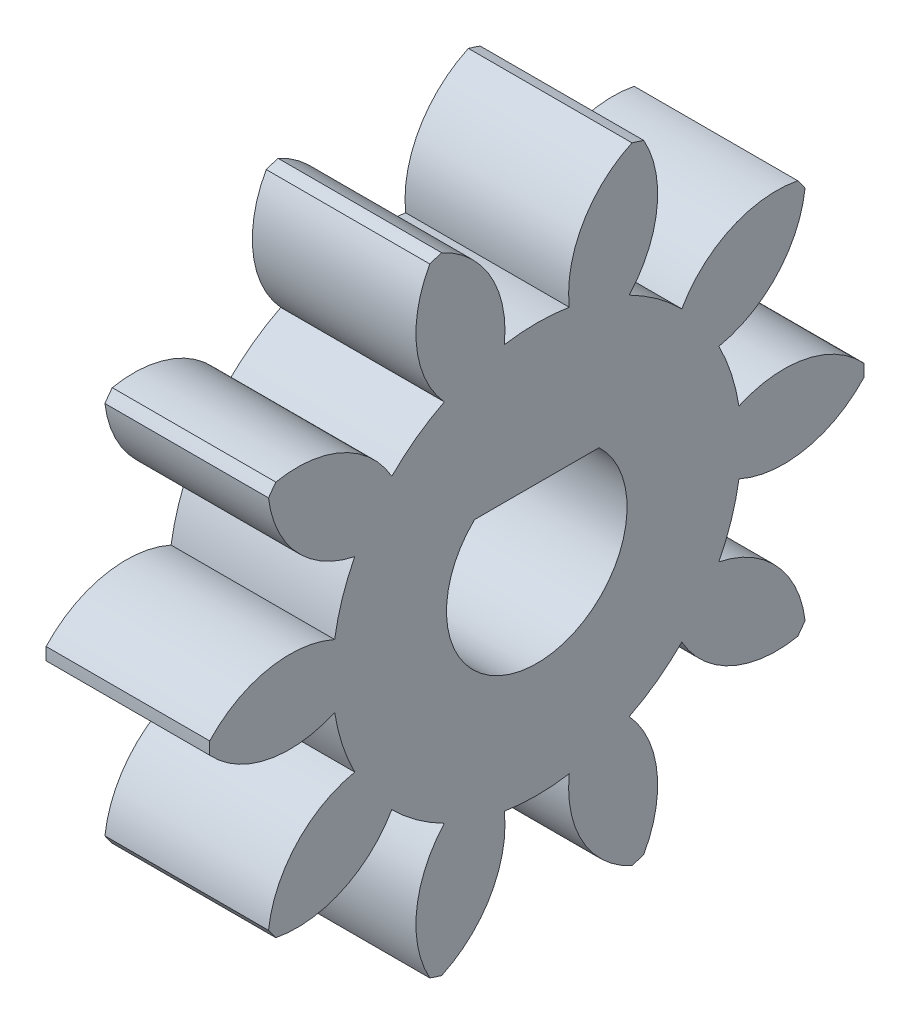
from build123d import *

# Parameters (mm, degrees)
BASPROSKE_W        = 3.175
BASPROSKE_H        = 6.35
TOOTHCUT_DEPTH     = 10.525
TEETHCUTS_COUNT    = 10
TEETHCUTS_ANGLE    = 324
BORSKE_R           = 0.99949
BORE_DEPTH         = 50.8000508
CUT_EXTRUDE1_DEPTH = 10.344170464


with BuildPart() as part:
    # BasProSke → Base-Revolve (revolve)
    with BuildSketch(Plane(origin=(0, 0, 0), x_dir=(1, 0, 0), z_dir=(0, 1, 0)), mode=Mode.PRIVATE) as base_revolve_sk:
        with Locations((1.5875, 3.175)):
            Rectangle(BASPROSKE_W, BASPROSKE_H)
    revolve(base_revolve_sk.sketch.rotate(Axis((-10, 0, 0), (1, 0, 0)), 180), axis=Axis((-10, 0, 0), (1, 0, 0)))

    # TooCutSke → ToothCut (cut, through all)
    with BuildSketch(Plane(origin=(0, 0, 0), x_dir=(0, 0, -1), z_dir=(1, 0, 0))):
        with BuildLine():
            ThreePointArc((0.630210727, 3.920537785), (0, 3.970866667), (-0.630210727, 3.920537785))
            ThreePointArc((-0.630210727, 3.920537785), (-0.900510691, 5.2110639), (-1.88228345, 6.091201374))
            ThreePointArc((-1.88228345, 6.091201374), (0, 6.3754), (1.88228345, 6.091201374))
            ThreePointArc((1.88228345, 6.091201374), (0.900510691, 5.2110639), (0.630210727, 3.920537785))
        make_face()
    toothcut = extrude(amount=TOOTHCUT_DEPTH, mode=Mode.SUBTRACT)

    # TeethCuts: ToothCut ×10 about axis
    teethcuts_axis = Axis((-10, 0, 0), (1, 0, 0))
    for i in range(1, TEETHCUTS_COUNT):
        add(toothcut.rotate(teethcuts_axis, i * TEETHCUTS_ANGLE / (TEETHCUTS_COUNT - 1)), mode=Mode.SUBTRACT)

    # BorSke → Bore (cut, symmetric)
    with BuildSketch(Plane(origin=(0, 0, 0), x_dir=(0, 0, -1), z_dir=(1, 0, 0))):
        with Locations(Location((0, 0, 0), (0, 0, 180))):
            Circle(BORSKE_R)
    extrude(amount=BORE_DEPTH, both=True, mode=Mode.SUBTRACT)

    # Sketch1 → Cut-Extrude1 (cut, through all)
    with BuildSketch(Plane(origin=(3.175, 0, 0), x_dir=(0, 0, -1), z_dir=(1, 0, 0))):
        with BuildLine():
            Line((-1.207769332, 1.27), (1.207769332, 1.27))
            ThreePointArc((1.207769332, 1.27), (0, -1.7526), (-1.207769332, 1.27))
        make_face()
    extrude(amount=-CUT_EXTRUDE1_DEPTH, mode=Mode.SUBTRACT)


solid = part.part
